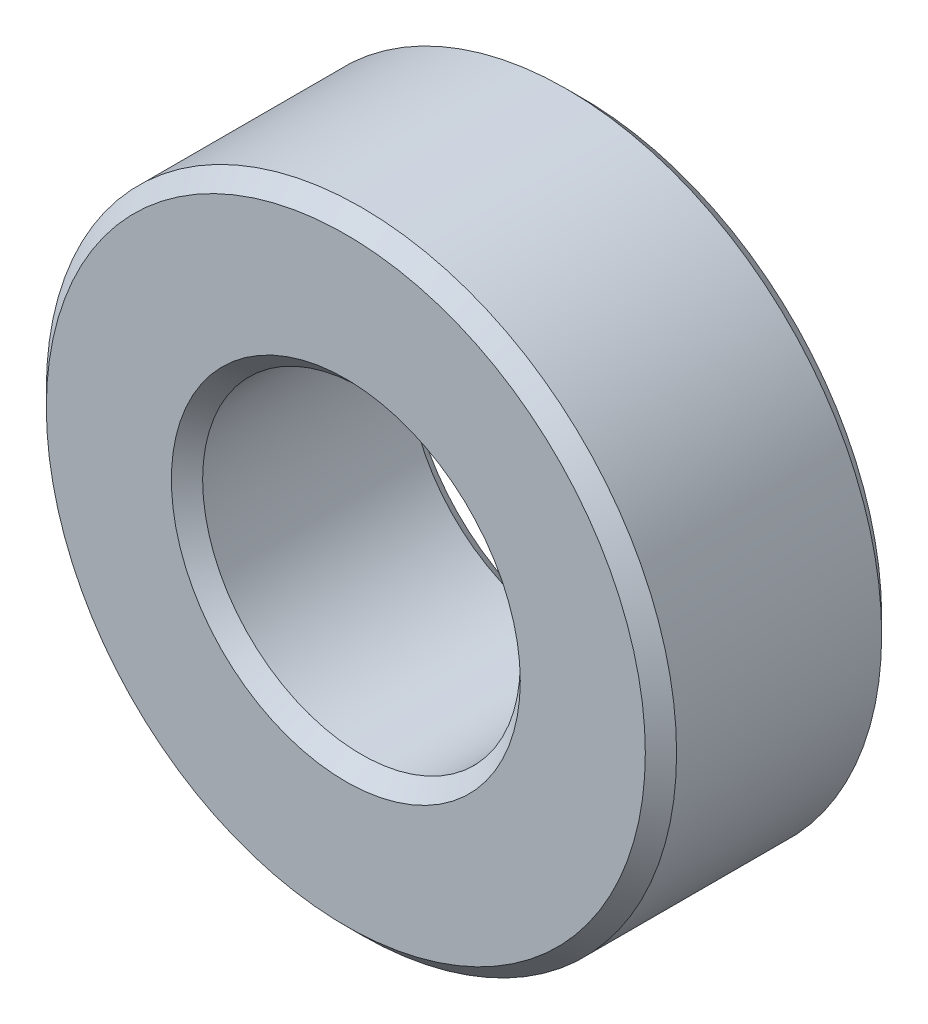
from build123d import *

# Parameters (mm, degrees)
SKETCH3_R                = 6.35
SKETCH3_R_2              = 3.2004
BOSS_EXTRUDE1_DEPTH      = 2.38125
BOSS_EXTRUDE1_DEPTH_BACK = 2.38125
CHAMFER1_SIZE            = 0.31496


with BuildPart() as part:
    # Sketch3 → Boss-Extrude1 (new body, two sides)
    with BuildSketch(Plane.XY) as boss_extrude1_sk:
        Circle(SKETCH3_R)
        Circle(SKETCH3_R_2, mode=Mode.SUBTRACT)
    extrude(amount=BOSS_EXTRUDE1_DEPTH)
    extrude(boss_extrude1_sk.sketch, amount=-BOSS_EXTRUDE1_DEPTH_BACK)

    # Chamfer1
    chamfer1_edges = [part.edges().sort_by_distance(p)[0] for p in [
        (-6.35, 0, -2.38125),
        (-3.2004, 0, -2.38125),
        (-6.35, 0, 2.38125),
        (-3.2004, 0, 2.38125),
    ]]
    chamfer(chamfer1_edges, length=CHAMFER1_SIZE)


solid = part.part
